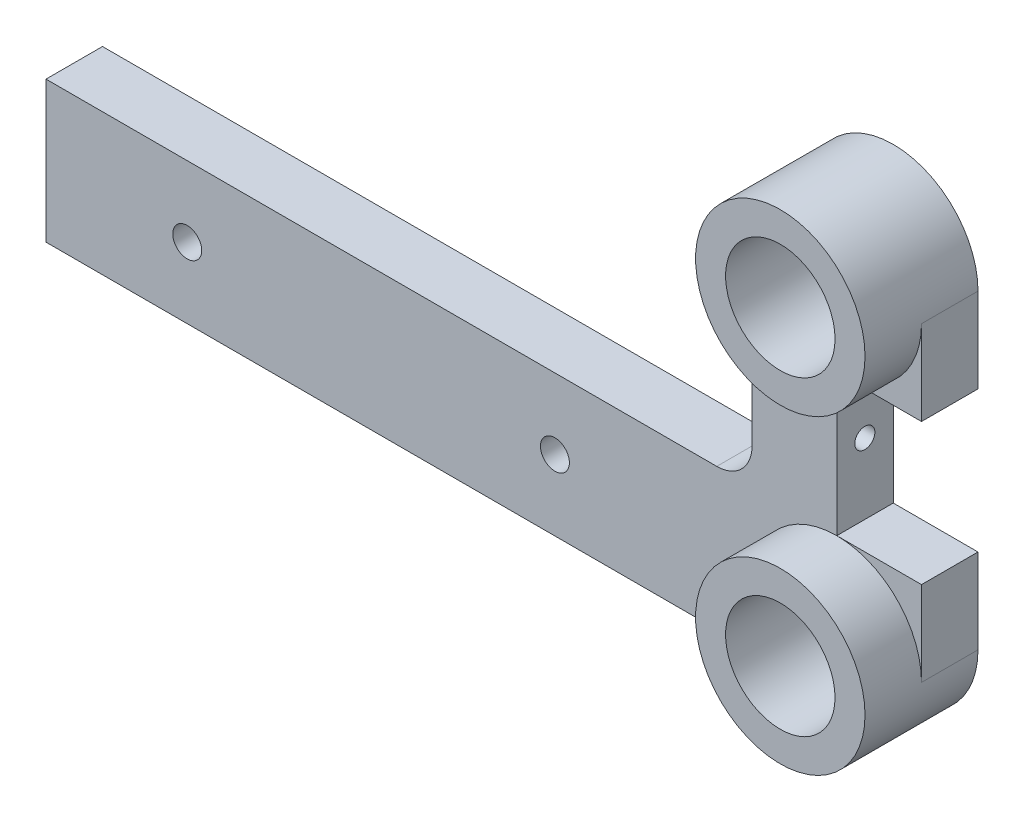
from build123d import *

# Parameters (mm, degrees)
BOSS_EXTRU_1_DEPTH                    = 8
ESQUISSE2_W                           = 8
ESQUISSE2_H                           = 20
BOSS_EXTRU_2_DEPTH                    = 100
BOSS_EXTRU_2_DEPTH_BACK               = 5
ESQUISSE3_R                           = 12
BOSS_EXTRU_3_DEPTH                    = 8
ESQUISSE4_R                           = 12
BOSS_EXTRU_4_DEPTH                    = 8
DIAM_TRE_DU_PER_AGE_4_1_4_1_1_D       = 4.1
DIAM_TRE_DU_PER_AGE_15_5_15_5_1_D     = 15.5
DIAM_TRE_DU_PER_AGE_15_5_15_5_1_DEPTH = 16
D_GAGEMENT_M2_51_D                    = 2.85
D_GAGEMENT_M2_51_DEPTH                = 10
CONG_1_R                              = 5


with BuildPart() as part:
    # Esquisse1 → Boss.-Extru.1 (new body)
    with BuildSketch(Plane.XY.offset(8)):
        with BuildLine():
            Line((-12, 44.000000179), (-12, 0))
            ThreePointArc((-12, 0), (0, -12), (12, 0))
            Line((12, 0), (12, 12))
            Line((12, 12), (0, 12))
            Line((0, 12), (0, 32))
            Line((0, 32), (12, 32))
            Line((12, 32), (12, 44.000000179))
            ThreePointArc((12, 44.000000179), (0, 56.000000179), (-12, 44.000000179))
        make_face()
    extrude(amount=-BOSS_EXTRU_1_DEPTH)

    # Esquisse2 → Boss.-Extru.2 (add, two sides)
    with BuildSketch(Plane.ZY.offset(12)) as boss_extru_2_sk:
        with Locations((4, 2)):
            Rectangle(ESQUISSE2_W, ESQUISSE2_H)
    extrude(amount=BOSS_EXTRU_2_DEPTH)
    extrude(boss_extru_2_sk.sketch, amount=-BOSS_EXTRU_2_DEPTH_BACK)

    # Esquisse3 → Boss.-Extru.3 (add)
    with BuildSketch(Plane.XY.offset(8)):
        with Locations((0, 44)):
            Circle(ESQUISSE3_R)
    extrude(amount=BOSS_EXTRU_3_DEPTH)

    # Esquisse4 → Boss.-Extru.4 (add)
    with BuildSketch(Plane.XY.offset(8)):
        Circle(ESQUISSE4_R)
    extrude(amount=BOSS_EXTRU_4_DEPTH)

    # Diamètre du perçage Ø4.1 (4.1)1 (through all)
    with Locations(Plane.XY.offset(8)):
        with Locations((-39.923806844, 2), (-92, 2)):
            Hole(DIAM_TRE_DU_PER_AGE_4_1_4_1_1_D / 2)

    # Diamètre du perçage Ø15.5 (15.5)1
    with Locations(Plane.XY.offset(16)):
        with Locations((0, 44), (0, 0)):
            Hole(DIAM_TRE_DU_PER_AGE_15_5_15_5_1_D / 2, depth=DIAM_TRE_DU_PER_AGE_15_5_15_5_1_DEPTH)

    # Dégagement M2.51
    with Locations(Plane(origin=(0, 0, 0), x_dir=(0, 0, -1), z_dir=(1, 0, 0))):
        with Locations((-4.029990313, 22)):
            Hole(D_GAGEMENT_M2_51_D / 2, depth=D_GAGEMENT_M2_51_DEPTH)

    # Congé1
    cong_1_edges = [part.edges().sort_by_distance(p)[0] for p in [
        (-12, 12, 4),
        (-8.94427191, -8, 4),
    ]]
    fillet(cong_1_edges, radius=CONG_1_R)


solid = part.part
